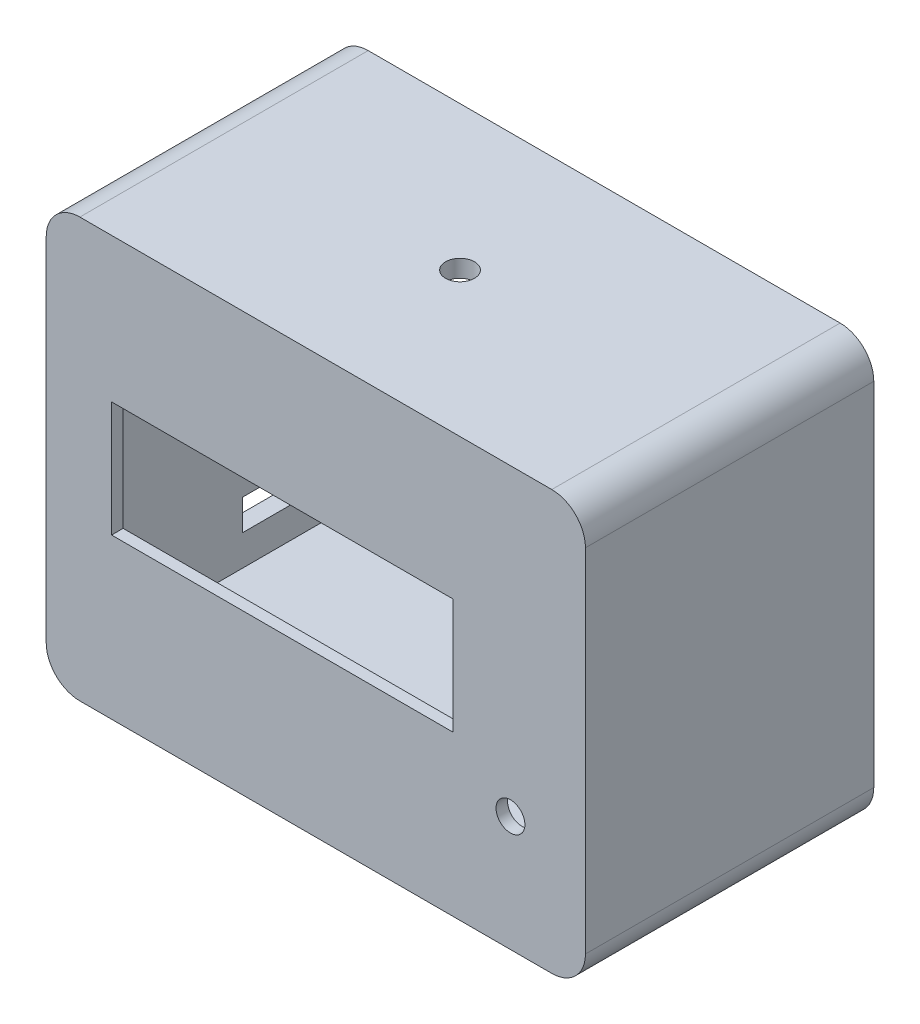
from build123d import *

# Parameters (mm, degrees)
SKETCH2_W           = 112.2
SKETCH2_H           = 87.2
SKETCH2_R           = 3
SKETCH2_W_2         = 71
SKETCH2_H_2         = 24
BOSS_EXTRUDE2_DEPTH = 60
SKETCH6_W           = 105
SKETCH6_H           = 80
CUT_EXTRUDE4_DEPTH  = 57.6
FILLET2_R           = 7
CUT_EXTRUDE5_REACH  = 89.2
SKETCH7_R           = 3
CUT_EXTRUDE6_REACH  = 114.2
SKETCH8_W           = 19.4
SKETCH8_H           = 6.4


with BuildPart() as part:
    # Sketch2 → Boss-Extrude2 (new body)
    with BuildSketch(Plane.XY):
        with Locations((3.248565438, 6.783112604)):
            Rectangle(SKETCH2_W, SKETCH2_H)
        with Locations((43.748565438, -12.816887396)):
            Circle(SKETCH2_R, mode=Mode.SUBTRACT)
        with Locations((-3.751434562, 8.383112604)):
            Rectangle(SKETCH2_W_2, SKETCH2_H_2, mode=Mode.SUBTRACT)
    extrude(amount=BOSS_EXTRUDE2_DEPTH)

    # Sketch6 → Cut-Extrude4 (cut)
    with BuildSketch(Plane(origin=(0, 0, 0), x_dir=(-1, 0, 0), z_dir=(0, 0, -1))):
        with Locations((-3.248565438, 6.783112604)):
            Rectangle(SKETCH6_W, SKETCH6_H)
    extrude(amount=-CUT_EXTRUDE4_DEPTH, mode=Mode.SUBTRACT)

    # Fillet2
    fillet2_edges = [part.edges().sort_by_distance(p)[0] for p in [
        (-52.851434562, 50.383112604, 30),
        (59.348565438, 50.383112604, 30),
        (59.348565438, -36.816887396, 30),
        (-52.851434562, -36.816887396, 30),
    ]]
    fillet(fillet2_edges, radius=FILLET2_R)

    # Sketch7 → Cut-Extrude5 (cut, up to next)
    with BuildSketch(Plane(origin=(0, 50.383112604, 0), x_dir=(1, 0, 0), z_dir=(0, 1, 0)), mode=Mode.PRIVATE) as cut_extrude5_sk1:
        with Locations((3.248565438, -30)):
            Circle(SKETCH7_R)
    cut_extrude5_tool1 = extrude(cut_extrude5_sk1.sketch, amount=-CUT_EXTRUDE5_REACH, mode=Mode.PRIVATE) & part.part
    add(cut_extrude5_tool1.solids().sort_by_distance((3.248565, 50.383113, 30))[0], mode=Mode.SUBTRACT)

    # Sketch8 → Cut-Extrude6 (cut, up to next)
    with BuildSketch(Plane.ZY.offset(52.851434562), mode=Mode.PRIVATE) as cut_extrude6_sk1:
        with Locations((13.1, -23.624199851)):
            Rectangle(SKETCH8_W, SKETCH8_H)
    cut_extrude6_tool1 = extrude(cut_extrude6_sk1.sketch, amount=-CUT_EXTRUDE6_REACH, mode=Mode.PRIVATE) & part.part
    add(cut_extrude6_tool1.solids().sort_by_distance((-52.851435, -23.6242, 13.1))[0], mode=Mode.SUBTRACT)


solid = part.part
